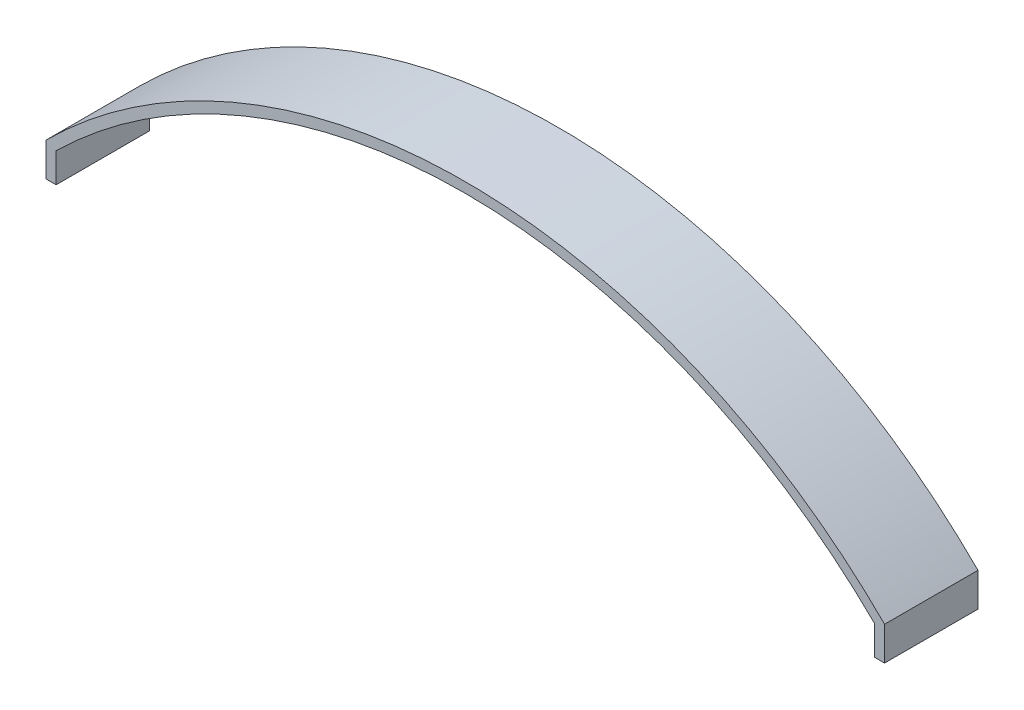
from build123d import *

# Parameters (mm, degrees)
BOSS_EXTRUDE1_DEPTH = 40.56


with BuildPart() as part:
    # Sketch1 → Boss-Extrude1 (new body)
    with BuildSketch(Plane.XY):
        with BuildLine():
            ThreePointArc((182, 14.613131648), (0, 90), (-182, 14.613131648))
            Line((-182, 14.613131648), (-182, 0))
            Line((-182, 0), (-177.6, 0))
            Line((-177.6, 0), (-177.6, 4.4))
            Line((-177.6, 4.4), (-177.6, 12.781374018))
            ThreePointArc((-177.6, 12.781374018), (0, 85.6), (177.6, 12.781374018))
            Line((177.6, 12.781374018), (177.6, 4.4))
            Line((177.6, 4.4), (177.6, 0))
            Line((177.6, 0), (182, 0))
            Line((182, 0), (182, 14.613131648))
        make_face()
    extrude(amount=-BOSS_EXTRUDE1_DEPTH)


solid = part.part
